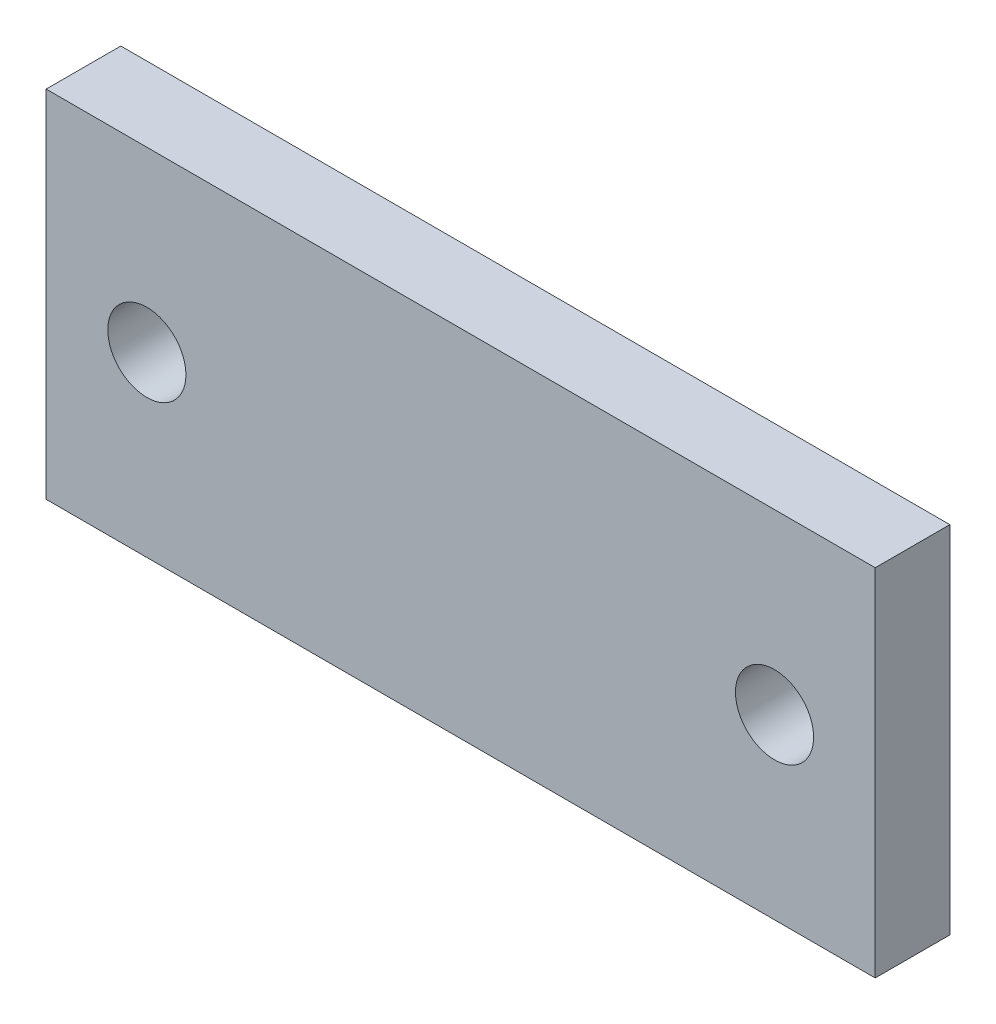
from build123d import *

# Parameters (mm, degrees)
SKETCH_1_W      = 70
SKETCH_1_H      = 30
SKETCH_1_R      = 3.3
EXTRUDE_1_DEPTH = 6.3


with BuildPart() as part:
    # 草图1 → 凸台-拉伸1 (new body)
    with BuildSketch(Plane.XY):
        Rectangle(SKETCH_1_W, SKETCH_1_H)
        with Locations((-26.5, 0)):
            Circle(SKETCH_1_R, mode=Mode.SUBTRACT)
        with Locations((26.5, 0)):
            Circle(SKETCH_1_R, mode=Mode.SUBTRACT)
    extrude(amount=EXTRUDE_1_DEPTH)


solid = part.part
